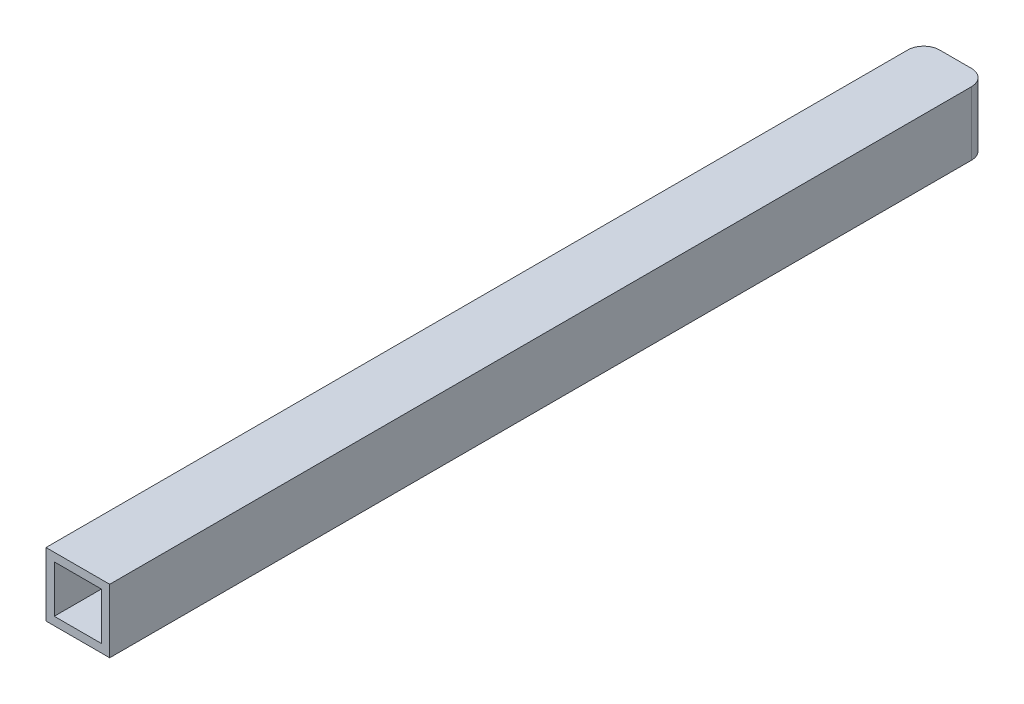
from build123d import *

# Parameters (mm, degrees)
SKETCH1_W           = 12.7
SKETCH1_H           = 12.7
SKETCH1_W_2         = 9.4
SKETCH1_H_2         = 9.4
BOSS_EXTRUDE1_DEPTH = 175
CUT_EXTRUDE1_DEPTH  = 13.7


with BuildPart() as part:
    # Sketch1 → Boss-Extrude1 (new body)
    with BuildSketch(Plane.XY):
        Rectangle(SKETCH1_W, SKETCH1_H)
        Rectangle(SKETCH1_W_2, SKETCH1_H_2, mode=Mode.SUBTRACT)
    extrude(amount=BOSS_EXTRUDE1_DEPTH)

    # Sketch2 → Cut-Extrude1 (cut, through all)
    with BuildSketch(Plane(origin=(0, 6.35, 0), x_dir=(1, 0, 0), z_dir=(0, 1, 0))):
        with BuildLine():
            Line((-6.35, -3.175), (-6.35, 0))
            Line((-6.35, 0), (-3.175, 0))
            ThreePointArc((-3.175, 0), (-5.42006403, -0.92993597), (-6.35, -3.175))
        make_face()
        with BuildLine():
            Line((3.175, 0), (6.35, 0))
            Line((6.35, 0), (6.35, -3.175))
            ThreePointArc((6.35, -3.175), (5.42006403, -0.92993597), (3.175, 0))
        make_face()
    extrude(amount=-CUT_EXTRUDE1_DEPTH, mode=Mode.SUBTRACT)


solid = part.part
